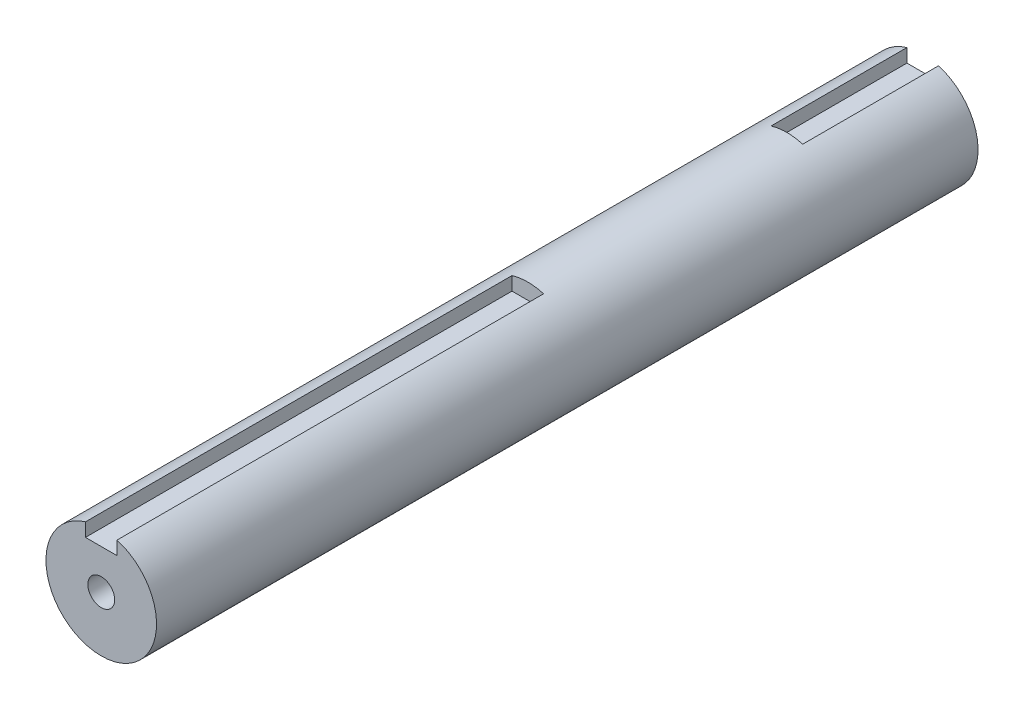
from build123d import *

# Parameters (mm, degrees)
ESQUISSE1_R             = 17.5
BOSS_EXTRU_1_DEPTH      = 260
ESQUISSE2_W             = 10
ESQUISSE2_H             = 5.634133163
ENL_V_MAT_EXTRU_1_DEPTH = 135
ESQUISSE3_W             = 10
ESQUISSE3_H             = 5.967992577
ENL_V_MAT_EXTRU_2_DEPTH = 43
TROU_TARAUD_M101_D      = 8.5
TROU_TARAUD_M101_DEPTH  = 46
TROU_TARAUD_M101_TIP    = 2.553657631


with BuildPart() as part:
    # Esquisse1 → Boss.-Extru.1 (new body)
    with BuildSketch(Plane.XY):
        Circle(ESQUISSE1_R)
    extrude(amount=BOSS_EXTRU_1_DEPTH)

    # Esquisse2 → Enlèv. mat.-Extru.1 (cut)
    with BuildSketch(Plane.XY.offset(260)):
        with Locations((0, 15.317066582)):
            Rectangle(ESQUISSE2_W, ESQUISSE2_H)
    extrude(amount=-ENL_V_MAT_EXTRU_1_DEPTH, mode=Mode.SUBTRACT)

    # Esquisse3 → Enlèv. mat.-Extru.2 (cut)
    with BuildSketch(Plane(origin=(0, 0, 0), x_dir=(-1, 0, 0), z_dir=(0, 0, -1))):
        with Locations((0, 15.483996289)):
            Rectangle(ESQUISSE3_W, ESQUISSE3_H)
    extrude(amount=-ENL_V_MAT_EXTRU_2_DEPTH, mode=Mode.SUBTRACT)

    # Trou taraudé M101
    with Locations(Plane.XY.offset(260)):
        with Locations((0, 0)):
            Hole(TROU_TARAUD_M101_D / 2, depth=TROU_TARAUD_M101_DEPTH)
            with Locations((0, 0, -(TROU_TARAUD_M101_DEPTH + TROU_TARAUD_M101_TIP / 2))):  # 118° drill point
                Cone(0, TROU_TARAUD_M101_D / 2, TROU_TARAUD_M101_TIP, mode=Mode.SUBTRACT)


solid = part.part
